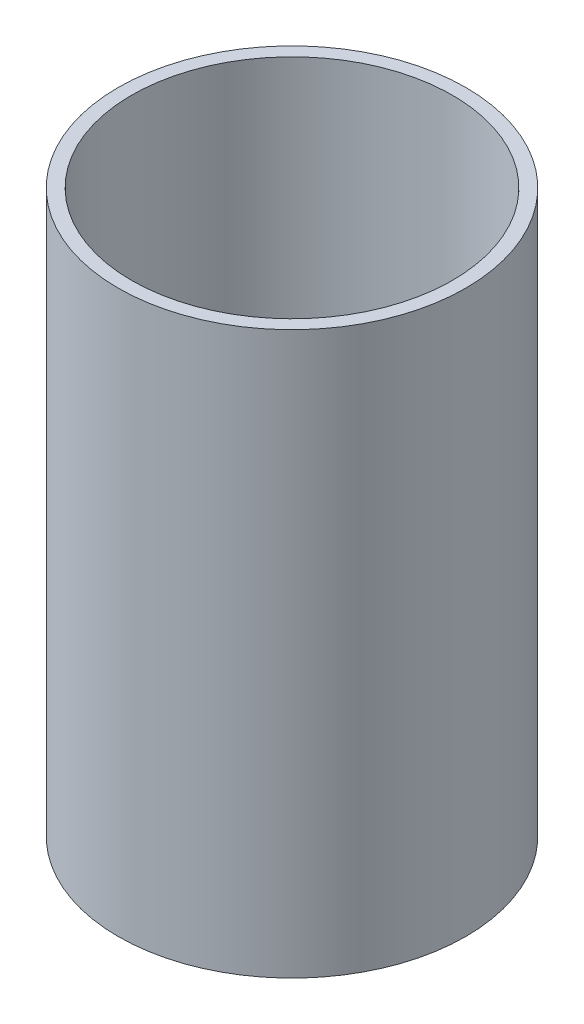
from build123d import *

# Parameters (mm, degrees)
SKETCH2_W = 3.175
SKETCH2_H = 133.35


with BuildPart() as part:
    # Sketch2 → Revolve1 (revolve)
    with BuildSketch(Plane.XY):
        with Locations((-39.6875, -66.675)):
            Rectangle(SKETCH2_W, SKETCH2_H)
    revolve(axis=Axis((0, 55, 0), (0, -1, 0)))


solid = part.part
